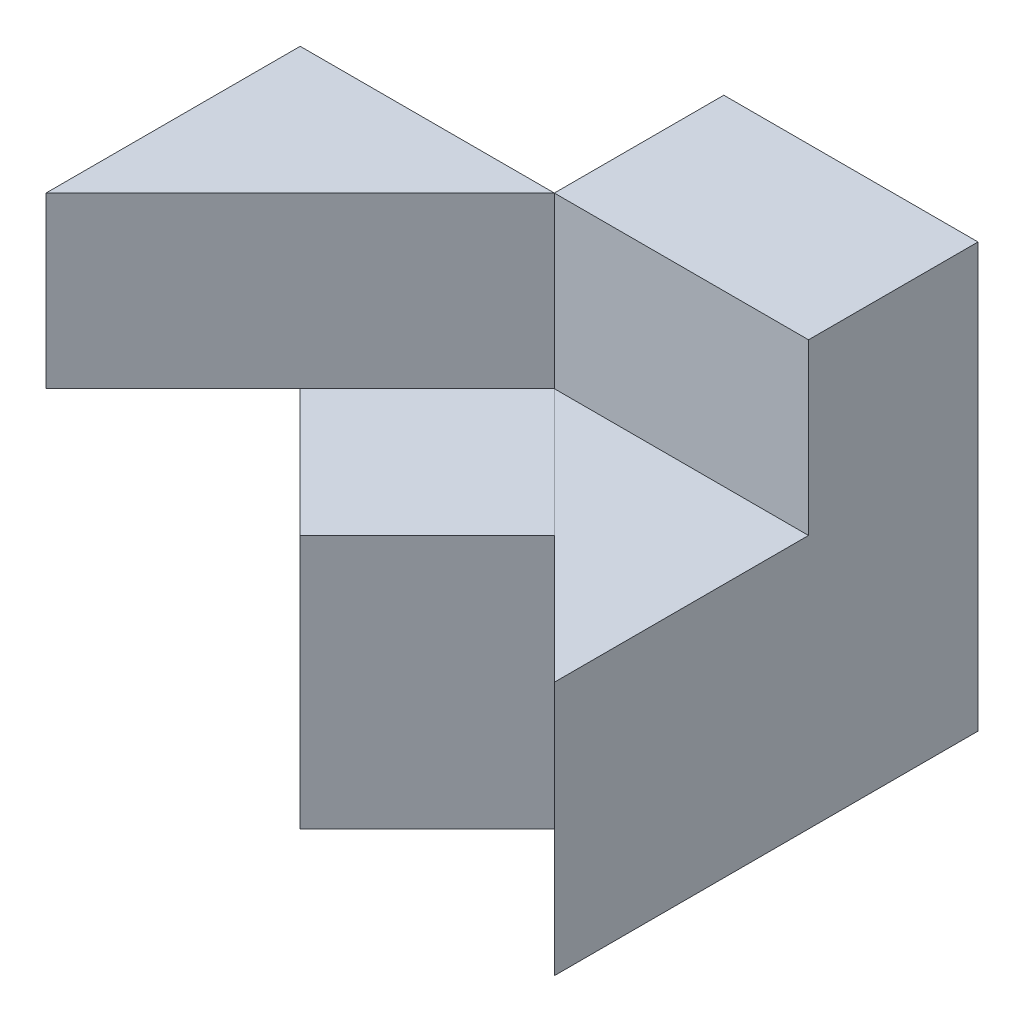
from build123d import *

# Parameters (mm, degrees)
SKETCH1_W            = 60
SKETCH1_H            = 50
BOSS_EXTRUDE1_DEPTH  = 50
SKETCH2_W            = 30
SKETCH2_H            = 20
CUT_EXTRUDE1_DEPTH   = 50
CUT_EXTRUDE2_DEPTH   = 50
SKETCH5_W            = 30
SKETCH5_H            = 20
CUT_EXTRUDE6_DEPTH   = 29.999
SKETCH7_W            = 29.999
SKETCH7_H            = 29.999
CUT_EXTRUDE10_DEPTH  = 29.999
CUT_EXTRUDE11_DEPTH  = 20
BOSS_EXTRUDE5_DEPTH  = 20
CUT_EXTRUDE17_DEPTH  = 0.0001
CUT_EXTRUDE18_DEPTH  = 0.0001
BOSS_EXTRUDE16_DEPTH = 0.0001


with BuildPart() as part:
    # Sketch1 → Boss-Extrude1 (new body)
    with BuildSketch(Plane.XY):
        with Locations((30, 25)):
            Rectangle(SKETCH1_W, SKETCH1_H)
    extrude(amount=BOSS_EXTRUDE1_DEPTH)

    # Sketch2 → Cut-Extrude1 (cut)
    with BuildSketch(Plane(origin=(0, 50, 0), x_dir=(1, 0, 0), z_dir=(0, 1, 0))):
        with Locations((15, -10)):
            Rectangle(SKETCH2_W, SKETCH2_H)
    extrude(amount=-CUT_EXTRUDE1_DEPTH, mode=Mode.SUBTRACT)

    # Sketch3 → Cut-Extrude2 (cut)
    with BuildSketch(Plane(origin=(0, 50, 0), x_dir=(1, 0, 0), z_dir=(0, 1, 0))):
        Polygon((15, -35), (0, -50), (30, -50), align=None)
        Polygon((45, -35), (30, -50), (60, -50), align=None)
    extrude(amount=-CUT_EXTRUDE2_DEPTH, mode=Mode.SUBTRACT)

    # Sketch5 → Cut-Extrude6 (cut)
    with BuildSketch(Plane.XY.offset(50)):
        with Locations((45, 40)):
            Rectangle(SKETCH5_W, SKETCH5_H)
    extrude(amount=-CUT_EXTRUDE6_DEPTH, mode=Mode.SUBTRACT)

    # Sketch7 → Cut-Extrude10 (cut)
    with BuildSketch(Plane.XY.offset(50)):
        with Locations((14.9995, 14.9995)):
            Rectangle(SKETCH7_W, SKETCH7_H)
    extrude(amount=-CUT_EXTRUDE10_DEPTH, mode=Mode.SUBTRACT)

    # Sketch8 → Cut-Extrude11 (cut)
    with BuildSketch(Plane(origin=(0, 50, 0), x_dir=(1, 0, 0), z_dir=(0, 1, 0))):
        Polygon((15, -35), (30, -20.001), (44.999, -35.001), (30, -50), align=None)
    extrude(amount=-CUT_EXTRUDE11_DEPTH, mode=Mode.SUBTRACT)

    # Sketch11 → Boss-Extrude5 (add)
    with BuildSketch(Plane(origin=(0, 50, 0), x_dir=(1, 0, 0), z_dir=(0, 1, 0))):
        Polygon((0, -50), (0, -20), (30, -20.001), align=None)
    extrude(amount=-BOSS_EXTRUDE5_DEPTH)

    # Sketch14 → Cut-Extrude17 (cut)
    with BuildSketch(Plane(origin=(0, 29.999, 0), x_dir=(-1, 0, 0), z_dir=(0, -1, 0))):
        Polygon((-15, -35), (0, -20.001), (0, -50), align=None)
    extrude(amount=-CUT_EXTRUDE17_DEPTH, mode=Mode.SUBTRACT)

    # Sketch15 → Cut-Extrude18 (cut)
    with BuildSketch(Plane(origin=(0, 0, 0), x_dir=(-1, 0, 0), z_dir=(0, -1, 0))):
        Polygon((-45, -35), (-60, -20), (-60, -50), align=None)
    extrude(amount=-CUT_EXTRUDE18_DEPTH, mode=Mode.SUBTRACT)

    # Sketch16 → Boss-Extrude16 (add)
    with BuildSketch(Plane(origin=(0, 30, 0), x_dir=(1, 0, 0), z_dir=(0, 1, 0))):
        Polygon((45, -35), (30, -20.001), (15.000250004, -35.000250004), (30, -50), align=None)
    extrude(amount=BOSS_EXTRUDE16_DEPTH)


solid = part.part
